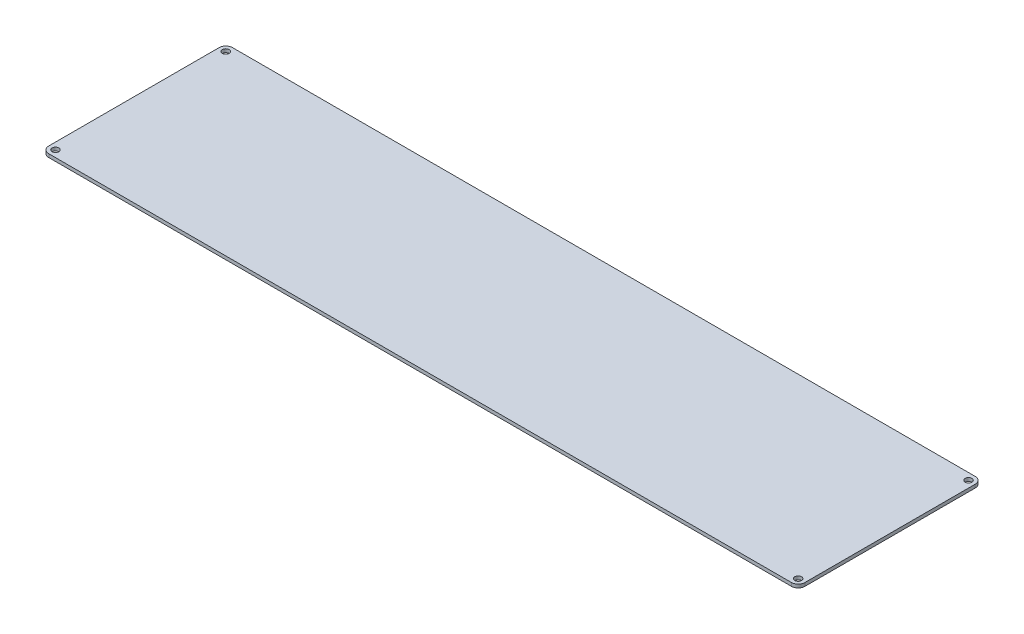
from build123d import *

# Parameters (mm, degrees)
SKETCH1_W           = 713.791017653
SKETCH1_H           = 173.482
SKETCH1_R           = 3.175
BOSS_EXTRUDE1_DEPTH = 3.175
FILLET1_R           = 6.35


with BuildPart() as part:
    # Sketch1 → Boss-Extrude1 (new body)
    with BuildSketch(Plane(origin=(0, 0, 0), x_dir=(1, 0, 0), z_dir=(0, 1, 0))):
        with Locations((-22.944046964, 112.256050824)):
            Rectangle(SKETCH1_W, SKETCH1_H)
        with Locations((327.601461862, 192.647050824)):
            Circle(SKETCH1_R, mode=Mode.SUBTRACT)
        with Locations((327.601461862, 31.865050824)):
            Circle(SKETCH1_R, mode=Mode.SUBTRACT)
        with Locations((-373.489555791, 31.865050824)):
            Circle(SKETCH1_R, mode=Mode.SUBTRACT)
        with Locations((-373.489555791, 192.647050824)):
            Circle(SKETCH1_R, mode=Mode.SUBTRACT)
    extrude(amount=-BOSS_EXTRUDE1_DEPTH)

    # Fillet1
    fillet1_edges = [part.edges().sort_by_distance(p)[0] for p in [
        (333.951461862, -1.5875, -25.515050824),
        (-379.839555791, -1.5875, -25.515050824),
        (-379.839555791, -1.5875, -198.997050824),
        (333.951461862, -1.5875, -198.997050824),
    ]]
    fillet(fillet1_edges, radius=FILLET1_R)


solid = part.part
